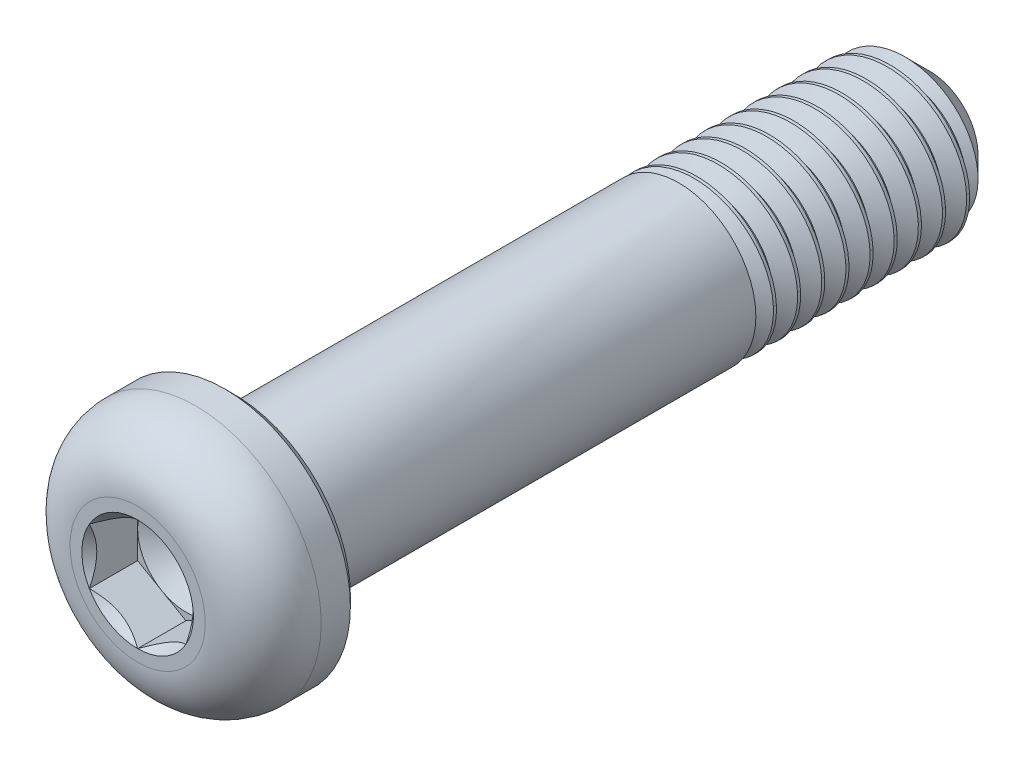
from build123d import *

# Parameters (mm, degrees)
CUT_EXTRUDE1_DEPTH     = 2.5
CUT_SWEEP1_PITCH       = 1.25
CUT_SWEEP1_HEIGHT      = 23.25
CUT_SWEEP1_RADIUS      = 4
CUT_SWEEP1_START_ANGLE = 90


with BuildPart() as part:
    # Sketch2 → Revolve1 (revolve)
    with BuildSketch(Plane(origin=(0, 0, 0), x_dir=(0, 0, -1), z_dir=(1, 0, 0)), mode=Mode.PRIVATE) as revolve1_sk:
        with BuildLine():
            Line((-20.4875, 6.5), (-20, 6.0125))
            Line((-20, 6.0125), (-20, 4.4))
            ThreePointArc((-20, 4.4), (-19.882842712, 4.117157288), (-19.6, 4))
            Line((-19.6, 4), (24.188101184, 4))
            Line((24.188101184, 4), (25, 3.188101184))
            Line((25, 3.188101184), (25, 0))
            Line((25, 0), (-22.5, 0))
            Line((-22.5, 0), (-22.5, 2.5))
            Line((-22.5, 2.5), (-25, 2.5))
            Line((-25, 2.5), (-25, 6.0125))
            Line((-25, 6.0125), (-24.5125, 6.5))
            Line((-24.5125, 6.5), (-20.4875, 6.5))
        make_face()
    revolve(revolve1_sk.sketch.rotate(Axis((0, 0, 22.5), (0, 0, -1)), 90), axis=Axis((0, 0, 22.5), (0, 0, -1)))

    # Sketch3 → Cut-Extrude1 (cut)
    with BuildSketch(Plane.XY.offset(25)):
        Polygon((0, 2.886751346), (-2.5, 1.443375673), (-2.5, -1.443375673), (0, -2.886751346), (2.5, -1.443375673), (2.5, 1.443375673), align=None)
    extrude(amount=-CUT_EXTRUDE1_DEPTH, mode=Mode.SUBTRACT)

    # Cut-Extrude2 cone 1 section (through the dimple's axis) → Cut-Extrude2 (revolve, cut)
    with BuildSketch(Plane(origin=(0, 0, 25), x_dir=(0, -1, 0), z_dir=(1, 0, 0))):
        Polygon((0, 0), (2.886751346, 0), (0, 2.886751346), align=None)
    revolve(axis=Axis((0, 0, 25), (0, 0, -1)), mode=Mode.SUBTRACT)

    # Cut-Extrude5 cone 1 section (through the dimple's axis) → Cut-Extrude5 (revolve, cut)
    with BuildSketch(Plane(origin=(0, 0, 22.5), x_dir=(0, -1, 0), z_dir=(1, 0, 0))):
        Polygon((0, 0), (2.5, 0), (0, 1.443375673), align=None)
    revolve(axis=Axis((0, 0, 22.5), (0, 0, -1)), mode=Mode.SUBTRACT)

    # Cut-Sweep1: sweep along a helix
    with BuildLine() as cut_sweep1_path:
        add(Helix(CUT_SWEEP1_PITCH, CUT_SWEEP1_HEIGHT, CUT_SWEEP1_RADIUS, center=(0, 0, -25), direction=(0, 0, 1), mode=Mode.PRIVATE).rotate(Axis((0, 0, -25), (0, 0, 1)), CUT_SWEEP1_START_ANGLE))
    # Sketch8 → Cut-Sweep1 (sweep, cut)
    with BuildSketch(Plane(origin=(0, 0, 0), x_dir=(0, 0, -1), z_dir=(1, 0, 0))):
        Polygon((24.9609375, 4.067658235), (26.1328125, 4.067658235), (25.625, 3.188101184), (25.46875, 3.188101184), align=None)
    sweep(path=cut_sweep1_path.line, is_frenet=True, mode=Mode.SUBTRACT)

    # Sketch9 → Revolve2 (revolve)
    with BuildSketch(Plane(origin=(0, 0, 0), x_dir=(0, 0, -1), z_dir=(1, 0, 0)), mode=Mode.PRIVATE) as revolve2_sk:
        Polygon((-21.056624327, 0), (-21.056624327, 4), (3, 4), (5.309401077, 0), align=None)
    revolve(revolve2_sk.sketch.rotate(Axis((0, 0, -5.309401077), (0, 0, 1)), 270), axis=Axis((0, 0, -5.309401077), (0, 0, 1)))


with BuildPart() as body_2:
    # Split1: the piece on the far side of the plane
    add(part.part)
    split(bisect_by=Plane(origin=(0, 0, -16), x_dir=(-1, 0, 0), z_dir=(0, 0, -1)), keep=Keep.BOTTOM)

    # Sketch10 → Cut-Revolve1 (revolve, cut)
    with BuildSketch(Plane(origin=(0, 0, 0), x_dir=(1, 0, 0), z_dir=(0, 1, 0)), mode=Mode.PRIVATE) as cut_revolve1_sk:
        Polygon((-2.5, 16), (-4, 14.5), (-4, 16), align=None)
        with BuildLine():
            Line((-3.5, -25), (-6.5, -25))
            Line((-6.5, -25), (-6.5, -22))
            ThreePointArc((-6.5, -22), (-5.621320344, -24.121320344), (-3.5, -25))
        make_face()
    revolve(cut_revolve1_sk.sketch.rotate(Axis((0, 0, -24.414209528), (0, 0, 1)), 180), axis=Axis((0, 0, -24.414209528), (0, 0, 1)), mode=Mode.SUBTRACT)


with BuildPart() as part_1:
    add(part.part)

    # Split1
    split(bisect_by=Plane(origin=(0, 0, -16), x_dir=(-1, 0, 0), z_dir=(0, 0, -1)), keep=Keep.TOP)


solid = body_2.part
